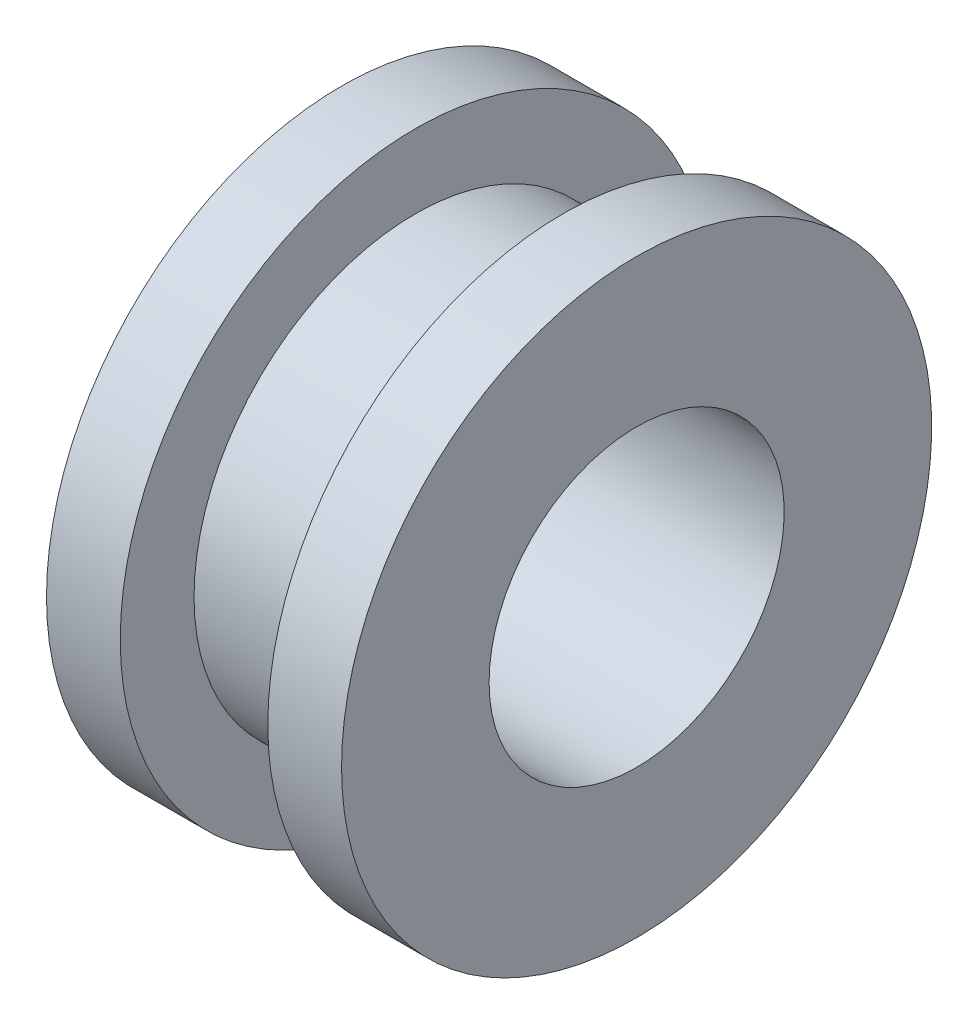
from build123d import *


with BuildPart() as part:
    # Esquisse1 → Révolution1 (revolve)
    with BuildSketch(Plane.XY):
        Polygon((-0.5, 1.5), (0.5, 1.5), (0.5, 2), (1, 2), (1, 1), (-1, 1), (-1, 2), (-0.5, 2), align=None)
    revolve(axis=Axis((-1.349929212, 0, 0), (1, 0, 0)))


solid = part.part
